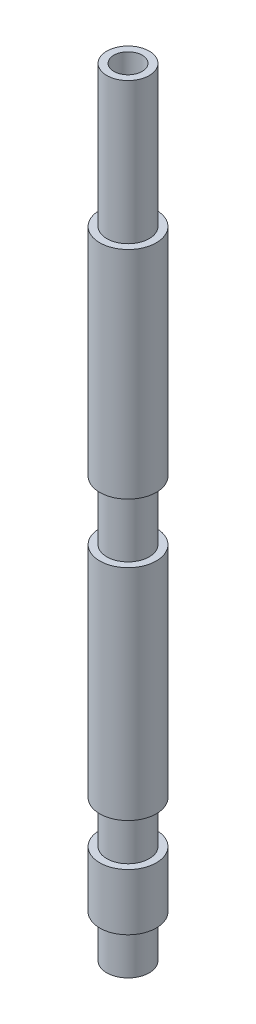
from build123d import *

# Parameters (mm, degrees)
SKETCH_1_R      = 2
SKETCH_1_R_2    = 1
EXTRUDE_1_DEPTH = 55
SKETCH_2_W      = 0.5
SKETCH_2_H      = 3
SKETCH_2_H_2    = 10
SKETCH_4_W      = 0.5
SKETCH_4_H      = 4.2


with BuildPart() as part:
    # Эскиз1 → Бобышка-Вытянуть1 (new body)
    with BuildSketch(Plane(origin=(0, 0, 0), x_dir=(1, 0, 0), z_dir=(0, 1, 0))):
        Circle(SKETCH_1_R)
        Circle(SKETCH_1_R_2, mode=Mode.SUBTRACT)
    extrude(amount=EXTRUDE_1_DEPTH)

    # Эскиз2 → Вырез-Повернуть1 (revolve, cut)
    with BuildSketch(Plane.XY):
        with Locations((1.75, 1.5)):
            Rectangle(SKETCH_2_W, SKETCH_2_H)
        with Locations((1.75, 8.5)):
            Rectangle(SKETCH_2_W, SKETCH_2_H)
        with Locations((1.75, 50)):
            Rectangle(SKETCH_2_W, SKETCH_2_H_2)
    revolve(axis=Axis((0, 0, 0), (0, 1, 0)), mode=Mode.SUBTRACT)

    # Эскиз4 → Вырез-Повернуть2 (revolve, cut)
    with BuildSketch(Plane.XY):
        with Locations((-1.75, 27.6)):
            Rectangle(SKETCH_4_W, SKETCH_4_H)
    revolve(axis=Axis((0, 0, 0), (0, 1, 0)), mode=Mode.SUBTRACT)


solid = part.part
